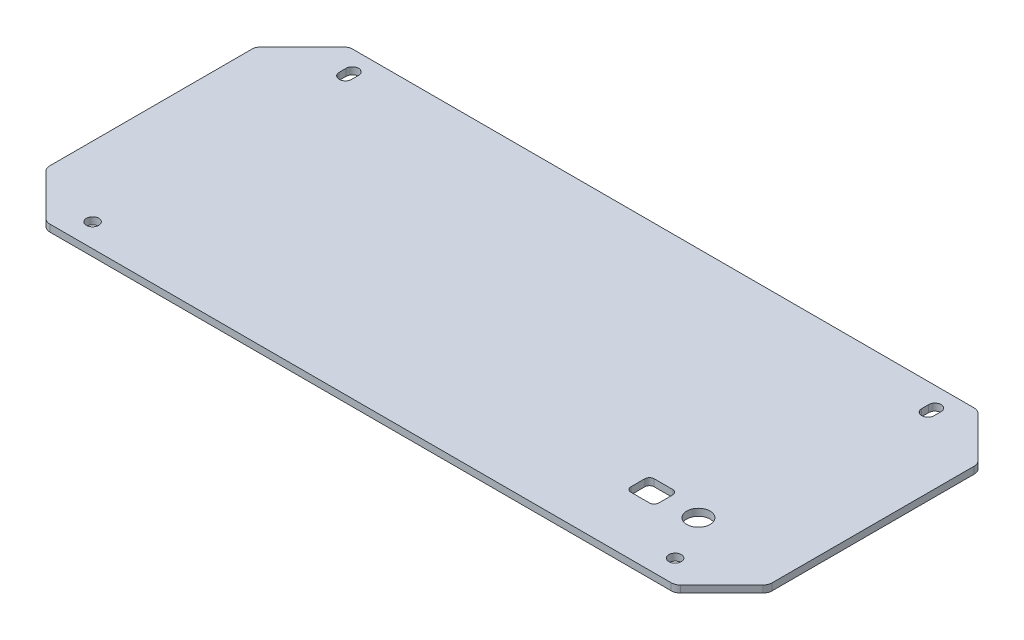
from build123d import *

# Parameters (mm, degrees)
SKETCH1_W                  = 310
SKETCH1_H                  = 130
BOSS_EXTRUDE1_DEPTH        = 3
CUT_EXTRUDE2_DEPTH         = 4
FILLET1_R                  = 4
F_5_3_5_3_DIAMETER_HOLE1_D = 5.3
SKETCH6_R                  = 5
SKETCH6_W                  = 12
SKETCH6_H                  = 10
CUT_EXTRUDE1_DEPTH         = 4
FILLET2_R                  = 2
CUT_EXTRUDE3_DEPTH         = 4


with BuildPart() as part:
    # Sketch1 → Boss-Extrude1 (new body)
    with BuildSketch(Plane(origin=(0, 0, 0), x_dir=(1, 0, 0), z_dir=(0, 1, 0))):
        Rectangle(SKETCH1_W, SKETCH1_H)
    extrude(amount=BOSS_EXTRUDE1_DEPTH)

    # Sketch7 → Cut-Extrude2 (cut, through all)
    with BuildSketch(Plane(origin=(0, 3, 0), x_dir=(1, 0, 0), z_dir=(0, 1, 0))):
        Polygon((-155, 65), (-155, 45), (-135, 65), align=None)
        Polygon((135, 65), (155, 65), (155, 45), align=None)
        Polygon((155, -65), (155, -45), (135, -65), align=None)
        Polygon((-135, -65), (-155, -65), (-155, -45), align=None)
    extrude(amount=-CUT_EXTRUDE2_DEPTH, mode=Mode.SUBTRACT)

    # Fillet1
    fillet1_edges = [part.edges().sort_by_distance(p)[0] for p in [
        (-155, 1.5, 45),
        (-135, 1.5, 65),
        (135, 1.5, 65),
        (155, 1.5, 45),
        (155, 1.5, -45),
        (135, 1.5, -65),
        (-135, 1.5, -65),
        (-155, 1.5, -45),
    ]]
    fillet(fillet1_edges, radius=FILLET1_R)

    # Ø5.3 (5.3) Diameter Hole1 (through all)
    with Locations(Plane(origin=(0, 3, 0), x_dir=(1, 0, 0), z_dir=(0, 1, 0))):
        with Locations((125, 55), (-125, -55), (-125, 55), (125, -55)):
            Hole(F_5_3_5_3_DIAMETER_HOLE1_D / 2)

    # Sketch6 → Cut-Extrude1 (cut, through all)
    with BuildSketch(Plane(origin=(0, 3, 0), x_dir=(1, 0, 0), z_dir=(0, 1, 0))):
        with Locations((115, -35)):
            Circle(SKETCH6_R)
        with Locations((95, -35)):
            Rectangle(SKETCH6_W, SKETCH6_H)
    extrude(amount=-CUT_EXTRUDE1_DEPTH, mode=Mode.SUBTRACT)

    # Fillet2
    fillet2_edges = [part.edges().sort_by_distance(p)[0] for p in [
        (101, 1.5, 30),
        (101, 1.5, 40),
        (89, 1.5, 40),
        (89, 1.5, 30),
    ]]
    fillet(fillet2_edges, radius=FILLET2_R)

    # Sketch8 → Cut-Extrude3 (cut, through all)
    with BuildSketch(Plane(origin=(0, 3, 0), x_dir=(1, 0, 0), z_dir=(0, 1, 0))):
        with BuildLine():
            Line((-127.65, 53.5), (-127.65, 56.5))
            ThreePointArc((-127.65, 56.5), (-125, 59.15), (-122.35, 56.5))
            Line((-122.35, 56.5), (-122.35, 53.5))
            ThreePointArc((-122.35, 53.5), (-125, 50.85), (-127.65, 53.5))
        make_face()
        with BuildLine():
            Line((122.35, 53.5), (122.35, 56.5))
            ThreePointArc((122.35, 56.5), (125, 59.15), (127.65, 56.5))
            Line((127.65, 56.5), (127.65, 53.5))
            ThreePointArc((127.65, 53.5), (125, 50.85), (122.35, 53.5))
        make_face()
    extrude(amount=-CUT_EXTRUDE3_DEPTH, mode=Mode.SUBTRACT)


solid = part.part
